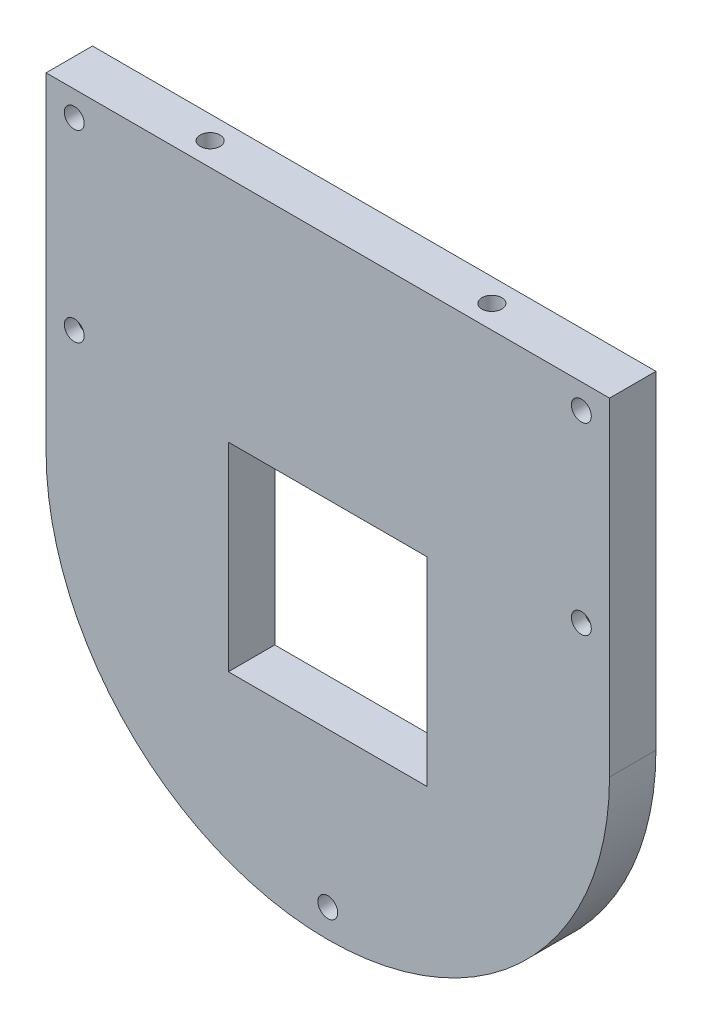
from build123d import *

# Parameters (mm, degrees)
SKETCH1_W           = 85
SKETCH1_H           = 95
BOSS_EXTRUDE1_DEPTH = 7
SKETCH2_W           = 30
SKETCH2_H           = 30
CUT_EXTRUDE1_DEPTH  = 7
SKETCH4_R           = 1.5
CUT_EXTRUDE2_DEPTH  = 10.5
SKETCH6_R           = 1.5
CUT_EXTRUDE3_DEPTH  = 8
CUT_EXTRUDE4_DEPTH  = 10
SKETCH8_R           = 1.5
CUT_EXTRUDE5_DEPTH  = 10
CUT_EXTRUDE6_DEPTH  = 5
SKETCH11_R          = 1.5
CUT_EXTRUDE8_DEPTH  = 4
SKETCH12_W          = 85
SKETCH12_H          = 7
CUT_EXTRUDE9_DEPTH  = 0.5


with BuildPart() as part:
    # Sketch1 → Boss-Extrude1 (new body)
    with BuildSketch(Plane.XY):
        with Locations((42.5, 47.5)):
            Rectangle(SKETCH1_W, SKETCH1_H)
    extrude(amount=BOSS_EXTRUDE1_DEPTH)

    # Sketch2 → Cut-Extrude1 (cut)
    with BuildSketch(Plane.XY.offset(7)):
        with Locations((42.5, 45)):
            Rectangle(SKETCH2_W, SKETCH2_H)
    extrude(amount=-CUT_EXTRUDE1_DEPTH, mode=Mode.SUBTRACT)

    # Sketch4 → Cut-Extrude2 (cut)
    with BuildSketch(Plane(origin=(0, 95, 0), x_dir=(1, 0, 0), z_dir=(0, 1, 0))):
        with Locations((21.25, -3.5)):
            Circle(SKETCH4_R)
        with Locations((63.75, -3.5)):
            Circle(SKETCH4_R)
    extrude(amount=-CUT_EXTRUDE2_DEPTH, mode=Mode.SUBTRACT)

    # Sketch6 → Cut-Extrude3 (cut)
    with BuildSketch(Plane(origin=(0, 0, 0), x_dir=(-1, 0, 0), z_dir=(0, 0, -1))):
        with Locations((-80.75, 90.75)):
            Circle(SKETCH6_R)
        with Locations((-4.25, 90.75)):
            Circle(SKETCH6_R)
        with Locations((-4.45, 4.25)):
            Circle(SKETCH6_R)
        with Locations((-80.75, 7.25)):
            Circle(SKETCH6_R)
    extrude(amount=-CUT_EXTRUDE3_DEPTH, mode=Mode.SUBTRACT)

    # Sketch7 → Cut-Extrude4 (cut)
    with BuildSketch(Plane(origin=(0, 0, 0), x_dir=(-1, 0, 0), z_dir=(0, 0, -1))):
        with BuildLine():
            Line((-85, 45), (-85, 0))
            Line((-85, 0), (0, 0))
            Line((0, 0), (0, 45))
            ThreePointArc((0, 45), (-42.5, 2.5), (-85, 45))
        make_face()
    extrude(amount=-CUT_EXTRUDE4_DEPTH, mode=Mode.SUBTRACT)

    # Sketch8 → Cut-Extrude5 (cut)
    with BuildSketch(Plane.XY.offset(7)):
        with Locations((80.75, 63)):
            Circle(SKETCH8_R)
        with Locations((4.25, 63)):
            Circle(SKETCH8_R)
    extrude(amount=-CUT_EXTRUDE5_DEPTH, mode=Mode.SUBTRACT)

    # Sketch9 → Cut-Extrude6 (cut)
    with BuildSketch(Plane(origin=(0, 0, 0), x_dir=(-1, 0, 0), z_dir=(0, 0, -1))):
        Polygon((-79.045, 65.953146627), (-82.455, 65.953146627), (-84.16, 63), (-82.455, 60.046853373), (-79.045, 60.046853373), (-77.34, 63), align=None)
        Polygon((-0.84, 63), (-2.545, 60.046853373), (-5.955, 60.046853373), (-7.66, 63), (-5.955, 65.953146627), (-2.545, 65.953146627), align=None)
    extrude(amount=-CUT_EXTRUDE6_DEPTH, mode=Mode.SUBTRACT)

    # Sketch11 → Cut-Extrude8 (cut)
    with BuildSketch(Plane.XY.offset(7)):
        with Locations((42.5, 6.75)):
            Circle(SKETCH11_R)
    extrude(amount=-CUT_EXTRUDE8_DEPTH, mode=Mode.SUBTRACT)

    # Sketch12 → Cut-Extrude9 (cut)
    with BuildSketch(Plane(origin=(0, 95, 0), x_dir=(1, 0, 0), z_dir=(0, 1, 0))):
        with Locations((42.5, -3.5)):
            Rectangle(SKETCH12_W, SKETCH12_H)
    extrude(amount=-CUT_EXTRUDE9_DEPTH, mode=Mode.SUBTRACT)


solid = part.part
